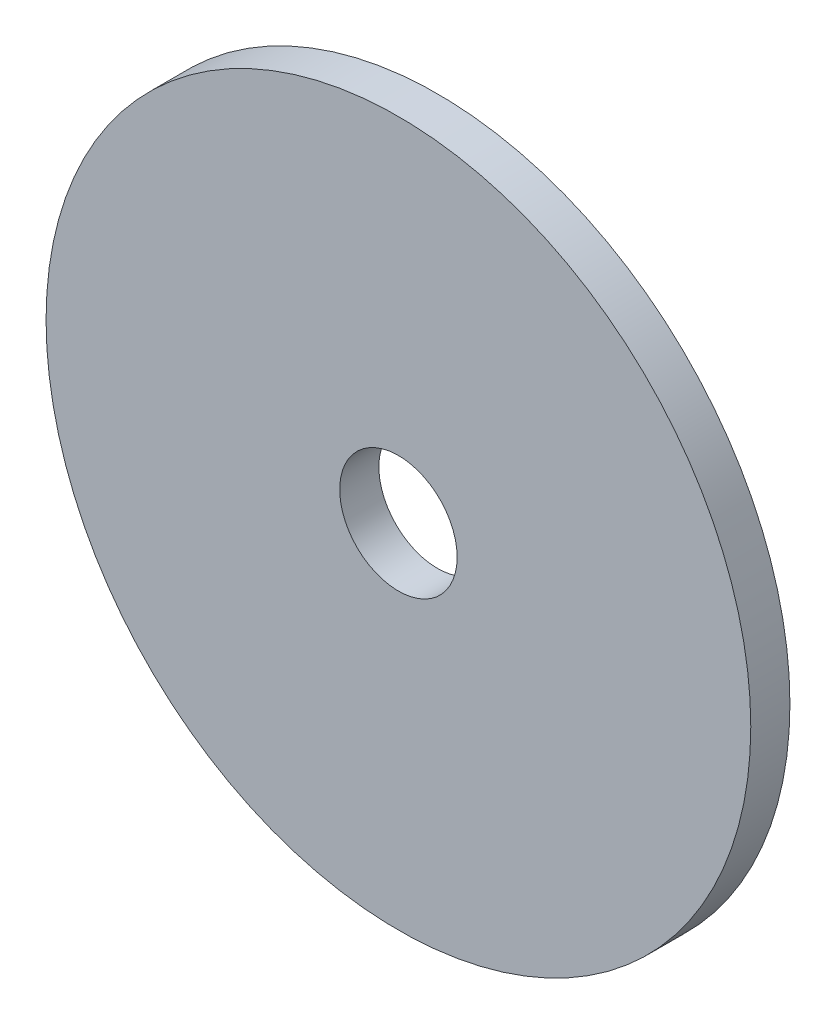
from build123d import *

# Parameters (mm, degrees)
SKETCH1_R           = 18
SKETCH1_R_2         = 3
BOSS_EXTRUDE1_DEPTH = 2


with BuildPart() as part:
    # Sketch1 → Boss-Extrude1 (new body)
    with BuildSketch(Plane.XY):
        Circle(SKETCH1_R)
        Circle(SKETCH1_R_2, mode=Mode.SUBTRACT)
    extrude(amount=BOSS_EXTRUDE1_DEPTH)


solid = part.part
